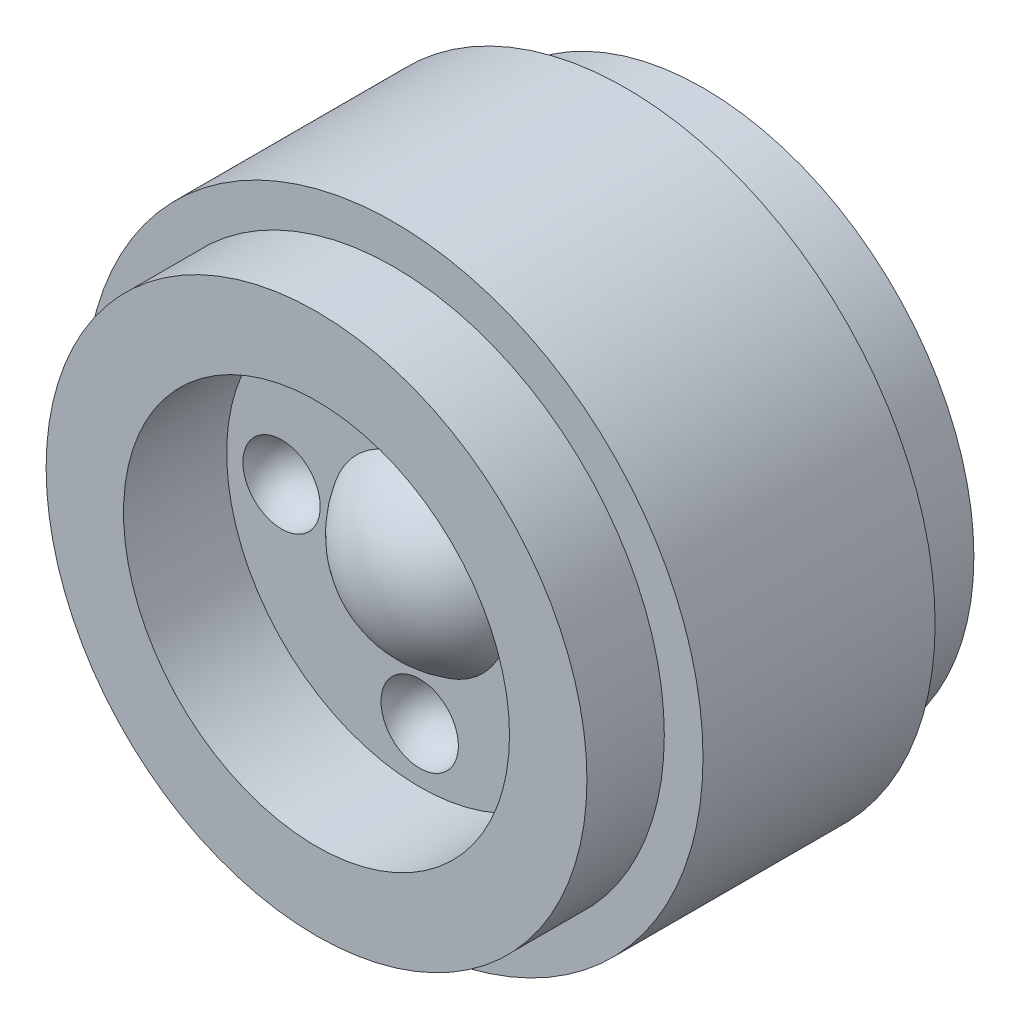
from build123d import *

# Parameters (mm, degrees)
CIRPATTERN1_COUNT = 4


with BuildPart() as part:
    # Sketch1 → Revolve1 (revolve)
    with BuildSketch(Plane(origin=(0, 0, 0), x_dir=(0, 0, -1), z_dir=(1, 0, 0))):
        with BuildLine():
            Line((-4.43484, 0), (1.61544, 0))
            Line((1.61544, 0), (1.61544, 3.2258))
            Line((1.61544, 3.2258), (6.05028, 3.2258))
            Line((6.05028, 3.2258), (6.05028, 8.45566))
            Line((6.05028, 8.45566), (3.62966, 8.45566))
            Line((3.62966, 8.45566), (3.62966, 9.6647))
            Line((3.62966, 9.6647), (-3.62966, 9.6647))
            Line((-3.62966, 9.6647), (-3.62966, 8.45566))
            Line((-3.62966, 8.45566), (-6.05028, 8.45566))
            Line((-6.05028, 8.45566), (-6.05028, 6.03504))
            Line((-6.05028, 6.03504), (-2.82448, 6.03504))
            Line((-2.82448, 6.03504), (-2.82448, 2.792156737))
            ThreePointArc((-2.82448, 2.792156737), (-4.003397886, 1.6116295), (-4.43484, 0))
        make_face()
    revolve(axis=Axis((0, 0, 4.43484), (0, 0, -1)))

    # Sketch2 → Cut-Revolve1 (revolve, cut)
    with BuildSketch(Plane.XY.offset(2.82448)):
        with BuildLine():
            Line((-1.20904, 4.318), (1.20904, 4.318))
            ThreePointArc((1.20904, 4.318), (0, 5.52704), (-1.20904, 4.318))
        make_face()
    cut_revolve1 = revolve(axis=Axis((-1.20904, 4.318, 2.82448), (1, 0, 0)), mode=Mode.SUBTRACT)

    # CirPattern1: Cut-Revolve1 ×4 about axis
    cirpattern1_axis = Axis((0, 0, 0), (0, 0, 1))
    for i in range(1, CIRPATTERN1_COUNT):
        add(cut_revolve1.rotate(cirpattern1_axis, i * 360 / CIRPATTERN1_COUNT), mode=Mode.SUBTRACT)


solid = part.part
